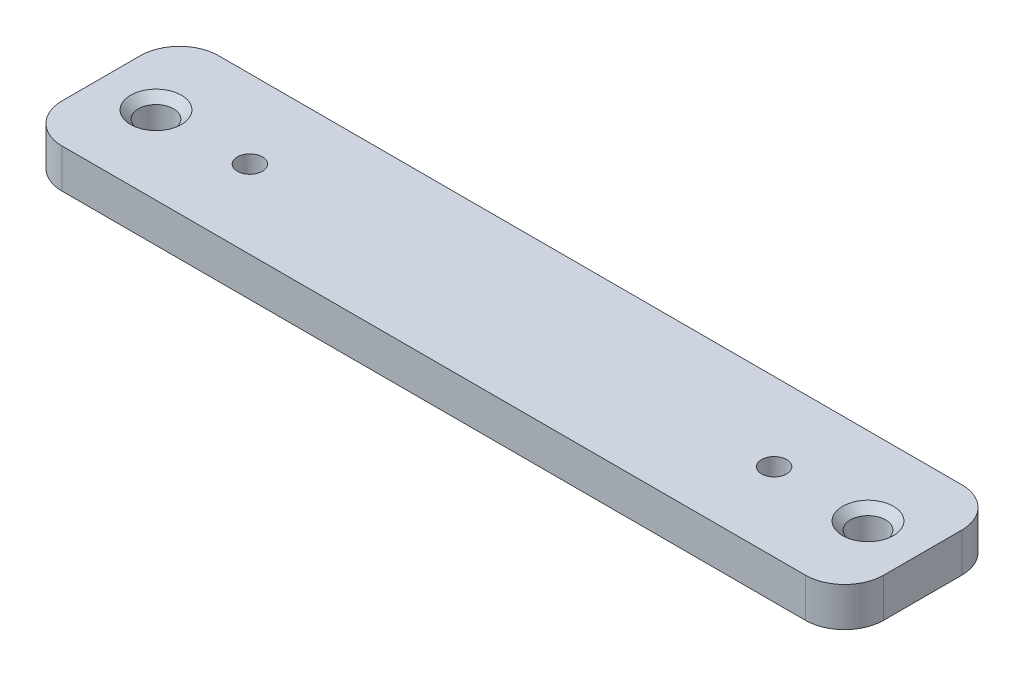
from build123d import *

# Parameters (mm, degrees)
SKETCH_1_W      = 105
SKETCH_1_H      = 20
SKETCH_1_R      = 1.6
SKETCH_1_R_2    = 2.25
EXTRUDE_1_DEPTH = 5
FILLET_2_R      = 5
CHAMFER_1_SIZE  = 1
CHAMFER_2_SIZE  = 1


with BuildPart() as part:
    # Эскиз1 → Бобышка-Вытянуть1 (new body)
    with BuildSketch(Plane(origin=(0, 0, 0), x_dir=(1, 0, 0), z_dir=(0, 1, 0))):
        with Locations((52.5, 10)):
            Rectangle(SKETCH_1_W, SKETCH_1_H)
        with Locations((19, 10)):
            Circle(SKETCH_1_R, mode=Mode.SUBTRACT)
        with Locations((86, 10)):
            Circle(SKETCH_1_R, mode=Mode.SUBTRACT)
        with Locations((7, 10)):
            Circle(SKETCH_1_R_2, mode=Mode.SUBTRACT)
        with Locations((98, 10)):
            Circle(SKETCH_1_R_2, mode=Mode.SUBTRACT)
    extrude(amount=EXTRUDE_1_DEPTH)

    # Скругление2
    fillet_2_edges = [part.edges().sort_by_distance(p)[0] for p in [
        (0, 2.5, -20),
        (105, 2.5, -20),
        (105, 2.5, 0),
        (0, 2.5, 0),
    ]]
    fillet(fillet_2_edges, radius=FILLET_2_R)

    # Фаска1
    chamfer_1_edges = [part.edges().sort_by_distance(p)[0] for p in [
        (4.75, 5, -10),
        (95.75, 5, -10),
    ]]
    chamfer(chamfer_1_edges, length=CHAMFER_1_SIZE)

    # Фаска2
    chamfer_2_edges = [part.edges().sort_by_distance(p)[0] for p in [
        (17.4, 0, -10),
        (84.4, 0, -10),
    ]]
    chamfer(chamfer_2_edges, length=CHAMFER_2_SIZE)


solid = part.part
